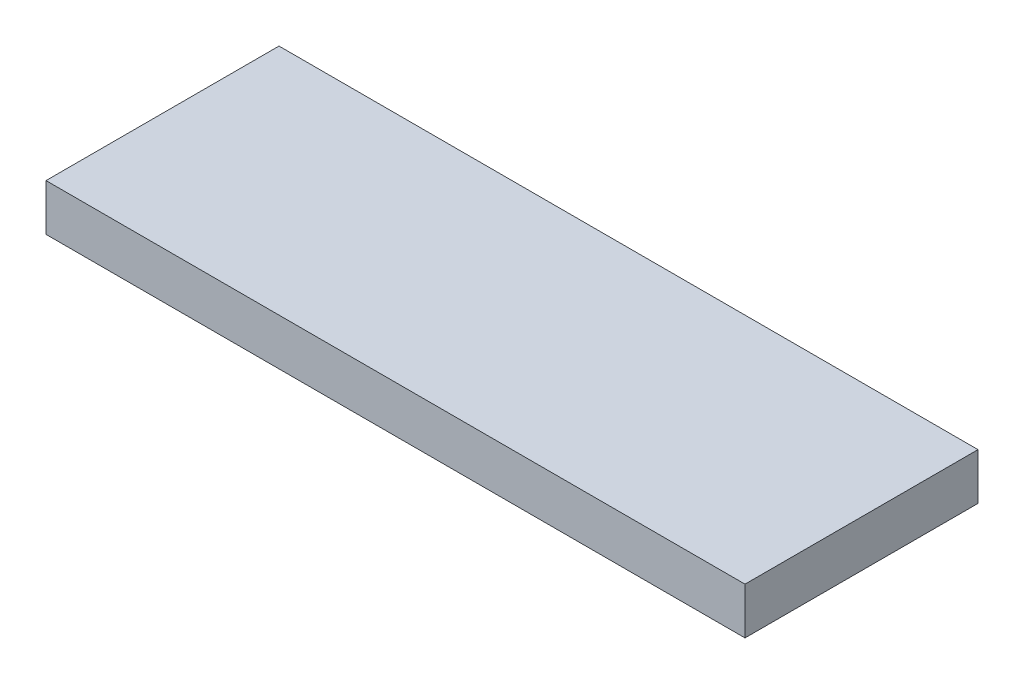
from build123d import *

# Parameters (mm, degrees)
SKETCH_1_W      = 30
SKETCH_1_H      = 10
EXTRUDE_1_DEPTH = 2


with BuildPart() as part:
    # Эскиз1 → Бобышка-Вытянуть1 (new body)
    with BuildSketch(Plane(origin=(0, 0, 0), x_dir=(1, 0, 0), z_dir=(0, 1, 0))):
        Rectangle(SKETCH_1_W, SKETCH_1_H)
    extrude(amount=EXTRUDE_1_DEPTH)


solid = part.part
